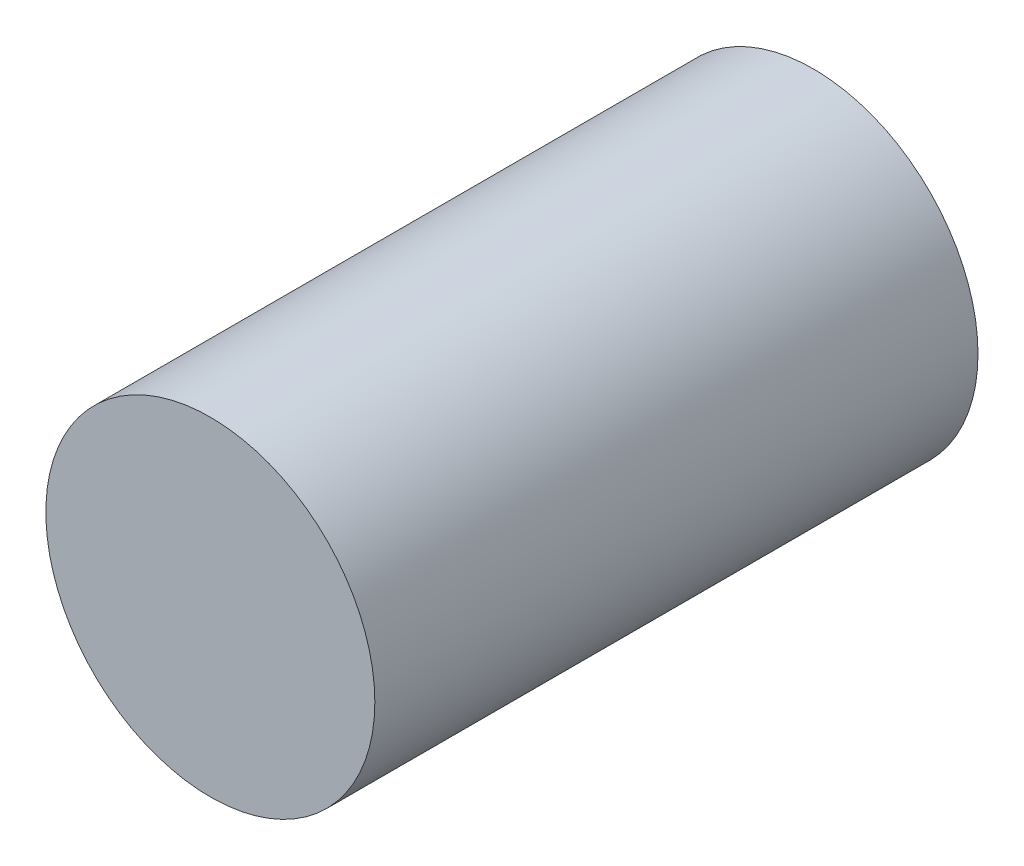
from build123d import *

# Parameters (mm, degrees)
ESQUISSE2_R        = 15
BOSS_EXTRU_1_DEPTH = 55


with BuildPart() as part:
    # Esquisse2 → Boss.-Extru.1 (new body)
    with BuildSketch(Plane.XY):
        Circle(ESQUISSE2_R)
    extrude(amount=BOSS_EXTRU_1_DEPTH)


solid = part.part
